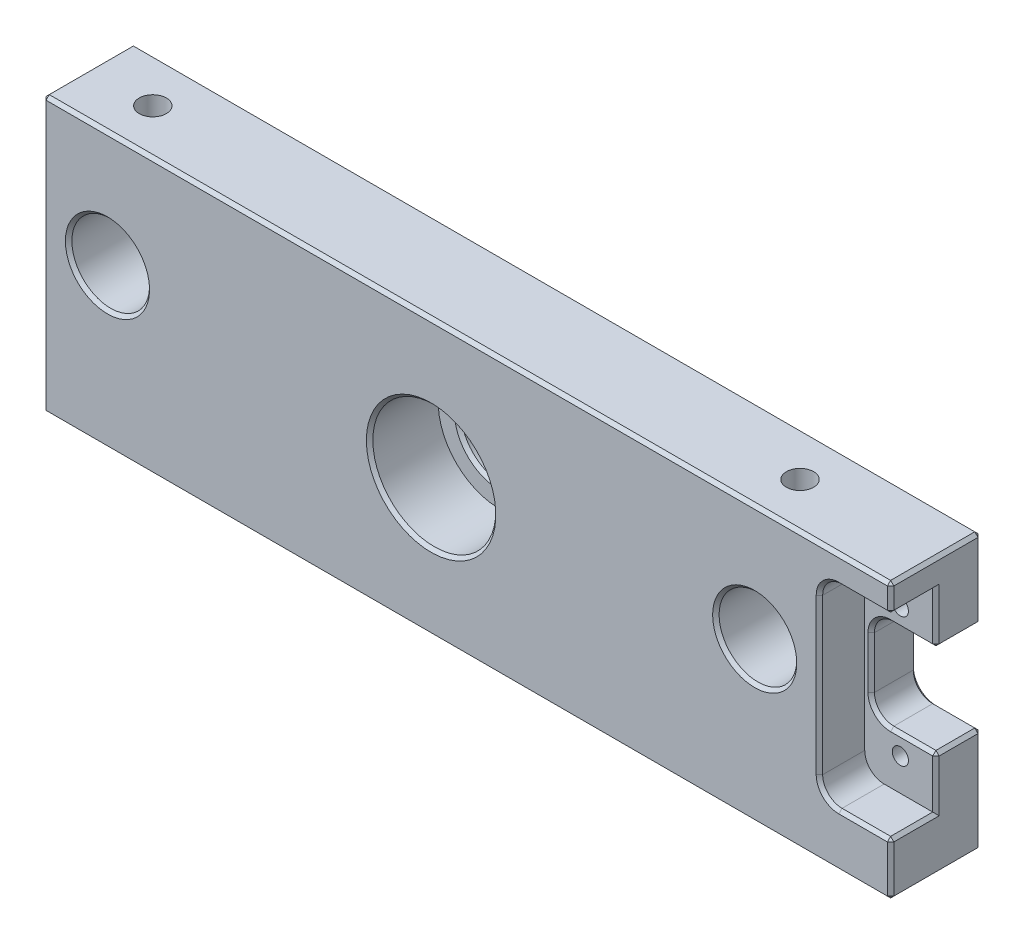
from build123d import *

# Parameters (mm, degrees)
SKETCH1_W                      = 120
SKETCH1_H                      = 42.5
BOSS_EXTRUDE1_DEPTH            = 7
SKETCH2_R                      = 9.5
CUT_EXTRUDE1_DEPTH             = 10.6
SKETCH3_R                      = 6.5
CUT_EXTRUDE2_DEPTH             = 65.528462712
SKETCH5_R                      = 6
CUT_EXTRUDE4_DEPTH             = 66.173326599
M5X0_8_TAPPED_HOLE1_AT_2_COUNT = 2
M5X0_8_TAPPED_HOLE1_AT_2_PITCH = 28
SKETCH19_R                     = 1.25
CUT_EXTRUDE7_DEPTH             = 10
M5X0_8_TAPPED_HOLE2_REACH      = 75.86
M5X0_8_TAPPED_HOLE2_BORE_R     = 2.1
SKETCH14_W                     = 14
SKETCH14_H                     = 42.5
BOSS_EXTRUDE2_DEPTH            = 11
SKETCH15_W                     = 11
SKETCH15_H                     = 30
CUT_EXTRUDE5_DEPTH             = 7
SKETCH16_W                     = 10
SKETCH16_H                     = 14
CUT_EXTRUDE6_DEPTH             = 75.441671835
FILLET1_R                      = 3
M3X0_5_TAPPED_HOLE1_D          = 2.5
CHAMFER1_SIZE                  = 0.5


with BuildPart() as part:
    # Sketch1 → Boss-Extrude1 (new, symmetric)
    with BuildSketch(Plane.XY):
        Rectangle(SKETCH1_W, SKETCH1_H)
    extrude(amount=BOSS_EXTRUDE1_DEPTH, both=True)

    # Sketch2 → Cut-Extrude1 (cut)
    with BuildSketch(Plane.XY.offset(7)):
        Circle(SKETCH2_R)
    extrude(amount=-CUT_EXTRUDE1_DEPTH, mode=Mode.SUBTRACT)

    # Sketch3 → Cut-Extrude2 (cut, through all)
    with BuildSketch(Plane.XY.offset(-3.6)):
        Circle(SKETCH3_R)
    extrude(amount=-CUT_EXTRUDE2_DEPTH, mode=Mode.SUBTRACT)

    # Sketch5 → Cut-Extrude4 (cut, through all)
    with BuildSketch(Plane.XY.offset(7)):
        with Locations((-50, 3.4)):
            Circle(SKETCH5_R)
        with Locations((50, 3.4)):
            Circle(SKETCH5_R)
    extrude(amount=-CUT_EXTRUDE4_DEPTH, mode=Mode.SUBTRACT)

    # Sketch8 → M5x0.8 Tapped Hole1 (revolve, cut)
    with BuildSketch(Plane(origin=(-22, -21.25, 0), x_dir=(0, 0, -1), z_dir=(1, 0, 0))):
        Polygon((0, 0), (0, 12.0618073), (2.1, 10.8), (2.1, 0), align=None)
    m5x0_8_tapped_hole1 = revolve(axis=Axis((-22, -27.6, 0), (0, 1, 0)), mode=Mode.SUBTRACT)

    # M5x0.8 Tapped Hole1 at 2: M5x0.8 Tapped Hole1 ×2
    with Locations(*[(-i * M5X0_8_TAPPED_HOLE1_AT_2_PITCH, 0, 0) for i in range(1, M5X0_8_TAPPED_HOLE1_AT_2_COUNT)]):
        add(m5x0_8_tapped_hole1, mode=Mode.SUBTRACT)

    # Sketch19 → Cut-Extrude7 (cut)
    with BuildSketch(Plane.XZ.offset(21.25)):
        with Locations(Location((-36, 0, 0), (0, 0, 270))):
            Circle(SKETCH19_R)
    cut_extrude7 = extrude(amount=-CUT_EXTRUDE7_DEPTH, mode=Mode.SUBTRACT)

    # Mirror1: M5x0.8 Tapped Hole1, Cut-Extrude7 across plane
    add(m5x0_8_tapped_hole1.mirror(Plane(origin=(0, 0, 0), x_dir=(0, 0, 1), z_dir=(1, 0, 0))), mode=Mode.SUBTRACT)
    add(cut_extrude7.mirror(Plane(origin=(0, 0, 0), x_dir=(0, 0, 1), z_dir=(1, 0, 0))), mode=Mode.SUBTRACT)

    # Mirror1 copy 1 sketch → Mirror1 copy 1 (revolve, cut)
    with BuildSketch(Plane(origin=(50, -21.25, 0), x_dir=(0, 0, -1), z_dir=(-1, 0, 0))):
        Polygon((0, 0), (0, -12.0618073), (2.1, -10.8), (2.1, 0), align=None)
    revolve(axis=Axis((50, -27.6, 0), (0, -1, 0)), mode=Mode.SUBTRACT)

    # M5x0.8 Tapped Hole2 bore → M5x0.8 Tapped Hole2 (cut, up to next)
    with BuildSketch(Plane(origin=(0, 21.25, 0), x_dir=(1, 0, 0), z_dir=(0, 1, 0)), mode=Mode.PRIVATE) as m5x0_8_tapped_hole2_sk1:
        with Locations((-50, 0)):
            Circle(M5X0_8_TAPPED_HOLE2_BORE_R)
    m5x0_8_tapped_hole2_tool1 = extrude(m5x0_8_tapped_hole2_sk1.sketch, amount=-M5X0_8_TAPPED_HOLE2_REACH, mode=Mode.PRIVATE) & part.part
    # M5x0.8 Tapped Hole2 bore → M5x0.8 Tapped Hole2 (cut, up to next)
    with BuildSketch(Plane(origin=(0, 21.25, 0), x_dir=(1, 0, 0), z_dir=(0, 1, 0)), mode=Mode.PRIVATE) as m5x0_8_tapped_hole2_sk2:
        with Locations((50, 0)):
            Circle(M5X0_8_TAPPED_HOLE2_BORE_R)
    m5x0_8_tapped_hole2_tool2 = extrude(m5x0_8_tapped_hole2_sk2.sketch, amount=-M5X0_8_TAPPED_HOLE2_REACH, mode=Mode.PRIVATE) & part.part
    add(m5x0_8_tapped_hole2_tool1.solids().sort_by_distance((-50, 21.25, 0))[0], mode=Mode.SUBTRACT)
    add(m5x0_8_tapped_hole2_tool2.solids().sort_by_distance((50, 21.25, 0))[0], mode=Mode.SUBTRACT)

    # Sketch14 → Boss-Extrude2 (add)
    with BuildSketch(Plane(origin=(60, 0, 0), x_dir=(0, 0, -1), z_dir=(1, 0, 0))):
        Rectangle(SKETCH14_W, SKETCH14_H)
    extrude(amount=BOSS_EXTRUDE2_DEPTH)

    # Sketch15 → Cut-Extrude5 (cut)
    with BuildSketch(Plane.XY.offset(7)):
        with Locations((65.5, 2)):
            Rectangle(SKETCH15_W, SKETCH15_H)
    extrude(amount=-CUT_EXTRUDE5_DEPTH, mode=Mode.SUBTRACT)

    # Sketch16 → Cut-Extrude6 (cut, through all)
    with BuildSketch(Plane.XY):
        with Locations((66, 2)):
            Rectangle(SKETCH16_W, SKETCH16_H)
    extrude(amount=-CUT_EXTRUDE6_DEPTH, mode=Mode.SUBTRACT)

    # Fillet1
    fillet1_edges = [part.edges().sort_by_distance(p)[0] for p in [
        (61, -5, -3.5),
        (61, 9, -3.5),
        (60, -13, 3.5),
        (60, 17, 3.5),
    ]]
    fillet(fillet1_edges, radius=FILLET1_R)

    # M3x0.5 Tapped Hole1 (through all)
    with Locations(Plane.XY):
        with Locations((65.5, 12), (65.5, -8)):
            Hole(M3X0_5_TAPPED_HOLE1_D / 2)

    # Chamfer1
    chamfer1_edges = [part.edges().sort_by_distance(p)[0] for p in [
        (-60, 0, 7),
        (71, 9, -3.5),
        (71, -5, -3.5),
        (67.5, 9, -7),
        (67.5, 9, 0),
        (67.5, -5, 0),
        (67.5, -5, -7),
        (61, 2, 0),
        (61, 2, -7),
        (67, -13, 7),
        (60, 2, 7),
        (61.878679656, -4.121320344, 0),
        (61.878679656, -4.121320344, -7),
        (60.878679656, -12.121320344, 7),
        (60.878679656, 16.121320344, 7),
        (61.878679656, 8.121320344, 0),
        (61.878679656, 8.121320344, -7),
        (5.5, -21.25, 7),
        (-9.5, 0, 7),
        (-6.5, 0, -7),
        (-6.5, 0, -3.6),
        (-56, 3.4, -7),
        (-56, 3.4, 7),
        (44, 3.4, -7),
        (44, 3.4, 7),
        (5.5, -21.25, -7),
        (-60, 0, -7),
        (5.5, 21.25, -7),
        (5.5, 21.25, 7),
        (71, 19.125, 7),
        (71, -21.25, 0),
        (71, -13.125, -7),
        (71, 21.25, 0),
        (-60, -21.25, 0),
        (-60, 21.25, 0),
        (71, -17.125, 7),
        (71, -9, 0),
        (71, 17, 3.5),
        (71, -13, 3.5),
        (67, 17, 7),
        (71, 13, 0),
        (71, 15.125, -7),
    ]]
    chamfer(chamfer1_edges, length=CHAMFER1_SIZE)


solid = part.part
